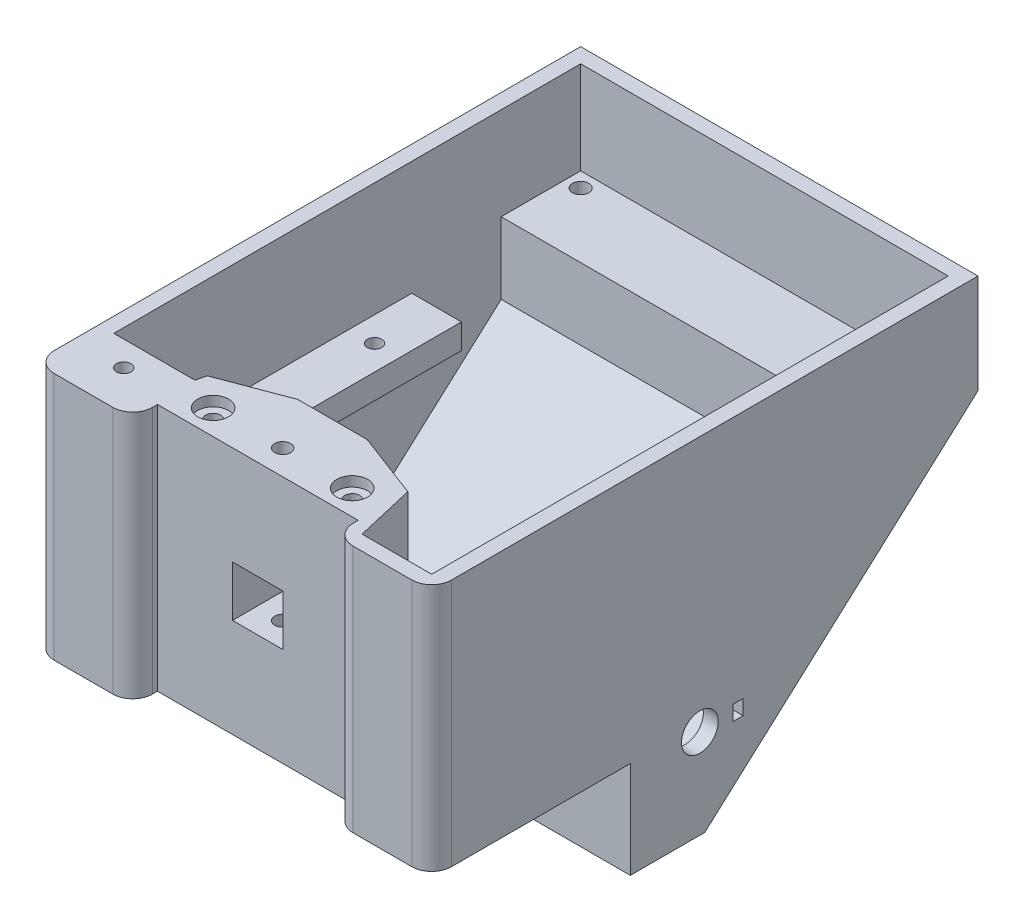
from build123d import *

# Parameters (mm, degrees)
BOSS_EXTRUDE1_DEPTH = 80
SHELL1_T            = -3
SKETCH3_W           = 46
SKETCH3_H           = 47
BOSS_EXTRUDE2_DEPTH = 17
SKETCH4_W           = 10.2
SKETCH4_H           = 10.2
CUT_EXTRUDE1_DEPTH  = 20
SKETCH6_W           = 15
SKETCH6_H           = 12.8
CUT_EXTRUDE2_DEPTH  = 3
SKETCH7_W           = 40.4
SKETCH7_H           = 50
CUT_EXTRUDE3_DEPTH  = 5
FILLET1_R           = 4
CUT_EXTRUDE7_DEPTH  = 47
SKETCH13_R          = 1.5
CUT_EXTRUDE8_DEPTH  = 25
SKETCH14_R          = 3.1
CUT_EXTRUDE9_DEPTH  = 2
SKETCH17_W          = 45
SKETCH17_H          = 5
BOSS_EXTRUDE5_DEPTH = 74
CUT_EXTRUDE10_REACH = 48.51
SKETCH18_W          = 54
SKETCH18_H          = 45
CUT_EXTRUDE11_REACH = 48.51
SKETCH19_R          = 1.45
BOSS_EXTRUDE6_DEPTH = 47
SKETCH22_R          = 1.45
CUT_EXTRUDE12_DEPTH = 70.509632224
CUT_EXTRUDE13_REACH = 82
SKETCH24_R          = 3.7
SKETCH24_W          = 2
SKETCH24_H          = 3
BOSS_EXTRUDE7_DEPTH = 74
SKETCH27_R          = 1.65
CUT_EXTRUDE14_DEPTH = 10
CUT_EXTRUDE15_START = -3
CUT_EXTRUDE15_DEPTH = 32
CUT_EXTRUDE16_DEPTH = 30
BOSS_EXTRUDE8_DEPTH = 20
SKETCH31_R          = 1.5
CUT_EXTRUDE17_DEPTH = 43.509632224
CUT_EXTRUDE18_DEPTH = 15
CUT_EXTRUDE19_REACH = 48.51
SKETCH33_W          = 10
SKETCH33_H          = 5
SKETCH34_R          = 1.6
CUT_EXTRUDE20_DEPTH = 70.509632224
CUT_EXTRUDE22_DEPTH = 14


with BuildPart() as part:
    # Sketch2 → Boss-Extrude1 (new body)
    with BuildSketch(Plane(origin=(0, 0, 0), x_dir=(0, 0, -1), z_dir=(1, 0, 0))):
        Polygon((-27.320490368, 20.998248687), (-27.320490368, -29.001751313), (12.679509632, -29.001751313), (12.679509632, -48.511383538), (27.679509632, -48.511383538), (82.679509632, 0.998248687), (82.679509632, 20.998248687), align=None)
    extrude(amount=BOSS_EXTRUDE1_DEPTH)

    # Shell1
    shell1_openings = [part.faces().sort_by_distance(p)[0] for p in [
        (40, 20.998248687, -27.679509632),
    ]]
    offset(amount=SHELL1_T, openings=shell1_openings, kind=Kind.INTERSECTION)

    # Sketch3 → Boss-Extrude2 (add)
    with BuildSketch(Plane(origin=(0, 0, 24.320490368), x_dir=(-1, 0, 0), z_dir=(0, 0, -1))):
        with Locations((-40, -2.501751313)):
            Rectangle(SKETCH3_W, SKETCH3_H)
    extrude(amount=BOSS_EXTRUDE2_DEPTH)

    # Sketch4 → Cut-Extrude1 (cut)
    with BuildSketch(Plane.XY.offset(27.320490368)):
        with Locations((40, -4.001751313)):
            Rectangle(SKETCH4_W, SKETCH4_H)
    extrude(amount=-CUT_EXTRUDE1_DEPTH, mode=Mode.SUBTRACT)

    # Sketch6 → Cut-Extrude2 (cut)
    with BuildSketch(Plane.XZ.offset(29.001751313)):
        with Locations((51.5, 0.920490368)):
            Rectangle(SKETCH6_W, SKETCH6_H)
        with Locations((28.5, 0.920490368)):
            Rectangle(SKETCH6_W, SKETCH6_H)
    extrude(amount=-CUT_EXTRUDE2_DEPTH, mode=Mode.SUBTRACT)

    # Sketch7 → Cut-Extrude3 (cut)
    with BuildSketch(Plane.XY.offset(27.320490368)):
        with Locations((40, -4.001751313)):
            Rectangle(SKETCH7_W, SKETCH7_H)
    extrude(amount=-CUT_EXTRUDE3_DEPTH, mode=Mode.SUBTRACT)

    # Fillet1
    fillet1_edges = [part.edges().sort_by_distance(p)[0] for p in [
        (19.8, -4.001751313, 27.320490368),
        (60.2, -4.001751313, 27.320490368),
        (80, -4.001751313, 27.320490368),
        (0, -4.001751313, 27.320490368),
    ]]
    fillet(fillet1_edges, radius=FILLET1_R)

    # Sketch12 → Cut-Extrude7 (cut)
    with BuildSketch(Plane(origin=(0, 20.998248687, 0), x_dir=(1, 0, 0), z_dir=(0, 1, 0))):
        Polygon((33, -7.320490368), (19.8, -12.320490368), (17, -24.320490368), (17, -7.320490368), align=None)
        Polygon((47, -7.320490368), (63, -7.320490368), (63, -24.320490368), (60.2, -12.320490368), align=None)
    extrude(amount=-CUT_EXTRUDE7_DEPTH, mode=Mode.SUBTRACT)

    # Sketch13 → Cut-Extrude8 (cut)
    with BuildSketch(Plane(origin=(0, 20.998248687, 0), x_dir=(1, 0, 0), z_dir=(0, 1, 0))):
        with Locations((26, -17.320490368)):
            Circle(SKETCH13_R)
        with Locations((54, -17.320490368)):
            Circle(SKETCH13_R)
    extrude(amount=-CUT_EXTRUDE8_DEPTH, mode=Mode.SUBTRACT)

    # Sketch14 → Cut-Extrude9 (cut)
    with BuildSketch(Plane(origin=(0, 20.998248687, 0), x_dir=(1, 0, 0), z_dir=(0, 1, 0))):
        with Locations((26, -17.320490368)):
            Circle(SKETCH14_R)
        with Locations((54, -17.320490368)):
            Circle(SKETCH14_R)
    extrude(amount=-CUT_EXTRUDE9_DEPTH, mode=Mode.SUBTRACT)

    # Sketch17 → Boss-Extrude5 (add)
    with BuildSketch(Plane.ZY.offset(-77)):
        with Locations((-23.179509632, -4.501751313)):
            Rectangle(SKETCH17_W, SKETCH17_H)
    extrude(amount=BOSS_EXTRUDE5_DEPTH)

    # Sketch18 → Cut-Extrude10 (cut, up to next)
    with BuildSketch(Plane(origin=(0, -2.001751313, 0), x_dir=(1, 0, 0), z_dir=(0, 1, 0)), mode=Mode.PRIVATE) as cut_extrude10_sk1:
        with Locations((40, 23.179509632)):
            Rectangle(SKETCH18_W, SKETCH18_H)
    cut_extrude10_tool1 = extrude(cut_extrude10_sk1.sketch, amount=-CUT_EXTRUDE10_REACH, mode=Mode.PRIVATE) & part.part
    add(cut_extrude10_tool1.solids().sort_by_distance((40, -2.001751, -23.17951))[0], mode=Mode.SUBTRACT)

    # Sketch19 → Cut-Extrude11 (cut, up to next)
    with BuildSketch(Plane(origin=(0, -2.001751313, 0), x_dir=(1, 0, 0), z_dir=(0, 1, 0)), mode=Mode.PRIVATE) as cut_extrude11_sk1:
        with Locations((72, 37.179509632)):
            Circle(SKETCH19_R)
    cut_extrude11_tool1 = extrude(cut_extrude11_sk1.sketch, amount=-CUT_EXTRUDE11_REACH, mode=Mode.PRIVATE) & part.part
    add(cut_extrude11_tool1.solids().sort_by_distance((72, -2.001751, -37.17951))[0], mode=Mode.SUBTRACT)
    # Sketch19 → Cut-Extrude11 (cut, up to next)
    with BuildSketch(Plane(origin=(0, -2.001751313, 0), x_dir=(1, 0, 0), z_dir=(0, 1, 0)), mode=Mode.PRIVATE) as cut_extrude11_sk2:
        with Locations((72, 6.179509632)):
            Circle(SKETCH19_R)
    cut_extrude11_tool2 = extrude(cut_extrude11_sk2.sketch, amount=-CUT_EXTRUDE11_REACH, mode=Mode.PRIVATE) & part.part
    add(cut_extrude11_tool2.solids().sort_by_distance((72, -2.001751, -6.17951))[0], mode=Mode.SUBTRACT)
    # Sketch19 → Cut-Extrude11 (cut, up to next)
    with BuildSketch(Plane(origin=(0, -2.001751313, 0), x_dir=(1, 0, 0), z_dir=(0, 1, 0)), mode=Mode.PRIVATE) as cut_extrude11_sk3:
        with Locations((8, 33.179509632)):
            Circle(SKETCH19_R)
    cut_extrude11_tool3 = extrude(cut_extrude11_sk3.sketch, amount=-CUT_EXTRUDE11_REACH, mode=Mode.PRIVATE) & part.part
    add(cut_extrude11_tool3.solids().sort_by_distance((8, -2.001751, -33.17951))[0], mode=Mode.SUBTRACT)
    # Sketch19 → Cut-Extrude11 (cut, up to next)
    with BuildSketch(Plane(origin=(0, -2.001751313, 0), x_dir=(1, 0, 0), z_dir=(0, 1, 0)), mode=Mode.PRIVATE) as cut_extrude11_sk4:
        with Locations((8, 6.179509632)):
            Circle(SKETCH19_R)
    cut_extrude11_tool4 = extrude(cut_extrude11_sk4.sketch, amount=-CUT_EXTRUDE11_REACH, mode=Mode.PRIVATE) & part.part
    add(cut_extrude11_tool4.solids().sort_by_distance((8, -2.001751, -6.17951))[0], mode=Mode.SUBTRACT)

    # Sketch21 → Boss-Extrude6 (add)
    with BuildSketch(Plane(origin=(0, -26.001751313, 0), x_dir=(1, 0, 0), z_dir=(0, 1, 0))):
        Polygon((3, -24.320490368), (3, -14.320490368), (19.333333333, -14.320490368), (17, -24.320490368), align=None)
    extrude(amount=BOSS_EXTRUDE6_DEPTH)

    # Sketch22 → Cut-Extrude12 (cut, through all)
    with BuildSketch(Plane(origin=(0, 20.998248687, 0), x_dir=(1, 0, 0), z_dir=(0, 1, 0))):
        with Locations((10, -19.320490368)):
            Circle(SKETCH22_R)
    extrude(amount=-CUT_EXTRUDE12_DEPTH, mode=Mode.SUBTRACT)

    # Sketch24 → Cut-Extrude13 (cut, up to next)
    with BuildSketch(Plane(origin=(80, 0, 0), x_dir=(0, 0, -1), z_dir=(1, 0, 0)), mode=Mode.PRIVATE) as cut_extrude13_sk1:
        with Locations((26.679509632, -30.511383538)):
            Circle(SKETCH24_R)
    cut_extrude13_tool1 = extrude(cut_extrude13_sk1.sketch, amount=-CUT_EXTRUDE13_REACH, mode=Mode.PRIVATE) & part.part
    add(cut_extrude13_tool1.solids().sort_by_distance((80, -30.511384, -26.67951))[0], mode=Mode.SUBTRACT)
    # Sketch24 → Cut-Extrude13 (cut, up to next)
    with BuildSketch(Plane(origin=(80, 0, 0), x_dir=(0, 0, -1), z_dir=(1, 0, 0)), mode=Mode.PRIVATE) as cut_extrude13_sk2:
        with Locations((34.379509632, -30.511383538)):
            Rectangle(SKETCH24_W, SKETCH24_H)
    cut_extrude13_tool2 = extrude(cut_extrude13_sk2.sketch, amount=-CUT_EXTRUDE13_REACH, mode=Mode.PRIVATE) & part.part
    add(cut_extrude13_tool2.solids().sort_by_distance((80, -30.511384, -34.37951))[0], mode=Mode.SUBTRACT)

    # Sketch26 → Boss-Extrude7 (add)
    with BuildSketch(Plane(origin=(3, 0, 0), x_dir=(0, 0, -1), z_dir=(1, 0, 0))):
        Polygon((79.679509632, 2.334161996), (63.679509632, 2.334161996), (63.679509632, -12.068640106), align=None)
    extrude(amount=BOSS_EXTRUDE7_DEPTH)

    # Sketch27 → Cut-Extrude14 (cut)
    with BuildSketch(Plane(origin=(0, 2.334161996, 0), x_dir=(1, 0, 0), z_dir=(0, 1, 0))):
        with Locations((6, 76.679509632)):
            Circle(SKETCH27_R)
        with Locations((74, 76.679509632)):
            Circle(SKETCH27_R)
    extrude(amount=-CUT_EXTRUDE14_DEPTH, mode=Mode.SUBTRACT)

    # Sketch28 → Cut-Extrude15 (cut)
    with BuildSketch(Plane(origin=(0, 2.334161996, 0), x_dir=(1, 0, 0), z_dir=(0, 1, 0)).offset(CUT_EXTRUDE15_START)):
        Polygon((74, 79.929509632), (71.185417438, 78.304509632), (71.185417438, 75.054509632), (74, 73.429509632), (76.814582562, 75.054509632), (76.814582562, 78.304509632), align=None)
        Polygon((6, 73.429509632), (8.814582562, 75.054509632), (8.814582562, 78.304509632), (6, 79.929509632), (3.185417438, 78.304509632), (3.185417438, 75.054509632), align=None)
    extrude(amount=-CUT_EXTRUDE15_DEPTH, mode=Mode.SUBTRACT)

    # Sketch29 → Cut-Extrude16 (cut)
    with BuildSketch(Plane.XZ.offset(29.001751313)):
        Polygon((7.185417438, 17.695490368), (10, 16.070490368), (12.814582562, 17.695490368), (12.814582562, 20.945490368), (10, 22.570490368), (7.185417438, 20.945490368), align=None)
    extrude(amount=-CUT_EXTRUDE16_DEPTH, mode=Mode.SUBTRACT)

    # Sketch30 → Boss-Extrude8 (add)
    with BuildSketch(Plane(origin=(0, -26.001751313, 0), x_dir=(1, 0, 0), z_dir=(0, 1, 0))):
        Polygon((77, -24.320490368), (63, -24.320490368), (60.2, -12.320490368), (77, -12.320490368), align=None)
    extrude(amount=BOSS_EXTRUDE8_DEPTH)

    # Sketch31 → Cut-Extrude17 (cut, through all)
    with BuildSketch(Plane(origin=(0, -6.001751313, 0), x_dir=(1, 0, 0), z_dir=(0, 1, 0))):
        with Locations((72, -21.320490368)):
            Circle(SKETCH31_R)
    extrude(amount=-CUT_EXTRUDE17_DEPTH, mode=Mode.SUBTRACT)

    # Sketch32 → Cut-Extrude18 (cut)
    with BuildSketch(Plane.XZ.offset(29.001751313)):
        Polygon((72, 24.570490368), (69.185417438, 22.945490368), (69.185417438, 19.695490368), (72, 18.070490368), (74.814582562, 19.695490368), (74.814582562, 22.945490368), align=None)
    extrude(amount=-CUT_EXTRUDE18_DEPTH, mode=Mode.SUBTRACT)

    # Sketch33 → Cut-Extrude19 (cut, up to next)
    with BuildSketch(Plane(origin=(0, -2.001751313, 0), x_dir=(1, 0, 0), z_dir=(0, 1, 0)), mode=Mode.PRIVATE) as cut_extrude19_sk1:
        with Locations((72, 43.179509632)):
            Rectangle(SKETCH33_W, SKETCH33_H)
    cut_extrude19_tool1 = extrude(cut_extrude19_sk1.sketch, amount=-CUT_EXTRUDE19_REACH, mode=Mode.PRIVATE) & part.part
    add(cut_extrude19_tool1.solids().sort_by_distance((72, -2.001751, -43.17951))[0], mode=Mode.SUBTRACT)

    # Sketch34 → Cut-Extrude20 (cut, through all)
    with BuildSketch(Plane(origin=(0, 20.998248687, 0), x_dir=(1, 0, 0), z_dir=(0, 1, 0))):
        with Locations((40, -17.320490368)):
            Circle(SKETCH34_R)
    extrude(amount=-CUT_EXTRUDE20_DEPTH, mode=Mode.SUBTRACT)

    # Sketch36 → Cut-Extrude22 (cut)
    with BuildSketch(Plane.XZ.offset(29.001751313)):
        Polygon((38.375, 20.13507293), (36.75, 17.320490368), (38.375, 14.505907805), (41.625, 14.505907805), (43.25, 17.320490368), (41.625, 20.13507293), align=None)
    extrude(amount=-CUT_EXTRUDE22_DEPTH, mode=Mode.SUBTRACT)


solid = part.part
